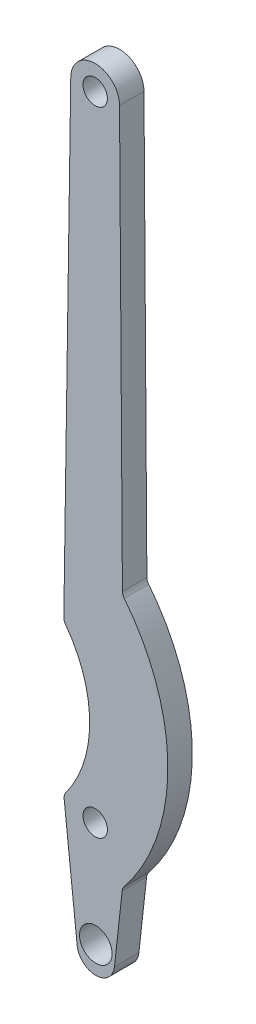
from build123d import *

# Parameters (mm, degrees)
SKETCH_1_R      = 1.5
SKETCH_1_R_2    = 2
EXTRUDE_1_DEPTH = 3


with BuildPart() as part:
    # 草图1 → 凸台-拉伸1 (new body)
    with BuildSketch(Plane.XY):
        with BuildLine():
            Line((-2.286729251, -0.246717108), (-3.883861716, 14.556510567))
            ThreePointArc((-3.883861716, 14.556510567), (-3.854723084, 14.925691914), (-3.693228018, 15.258953478))
            ThreePointArc((-3.693228018, 15.258953478), (-0.747195178, 24.211667814), (-3.723167614, 33.154474505))
            ThreePointArc((-3.723167614, 33.154474505), (-3.872965508, 33.444371631), (-3.921458744, 33.767060581))
            Line((-3.921458744, 33.767060581), (-3.069651306, 91.604785634))
            ThreePointArc((-3.069651306, 91.604785634), (-0.067427131, 94.551575772), (2.911665375, 91.581402384))
            Line((2.911665375, 91.581402384), (3.267124799, 40.124176415))
            ThreePointArc((3.267124799, 40.124176415), (3.324280751, 39.797782311), (3.484958279, 39.507984717))
            ThreePointArc((3.484958279, 39.507984717), (8.841844113, 24.158825584), (3.450331122, 8.821795246))
            ThreePointArc((3.450331122, 8.821795246), (3.307226898, 8.579714374), (3.237181652, 8.307362338))
            Line((3.237181652, 8.307362338), (2.285932959, -0.25398919))
            ThreePointArc((2.285932959, -0.25398919), (-0.003657774, -2.299997091), (-2.286729251, -0.246717108))
        make_face()
        with Locations((-0.07911944, 91.560742455)):
            Circle(SKETCH_1_R, mode=Mode.SUBTRACT)
        with Locations((-0.073800571, 13.899599644)):
            Circle(SKETCH_1_R, mode=Mode.SUBTRACT)
        with Locations((0, 1)):
            Circle(SKETCH_1_R_2, mode=Mode.SUBTRACT)
    extrude(amount=EXTRUDE_1_DEPTH)


solid = part.part
